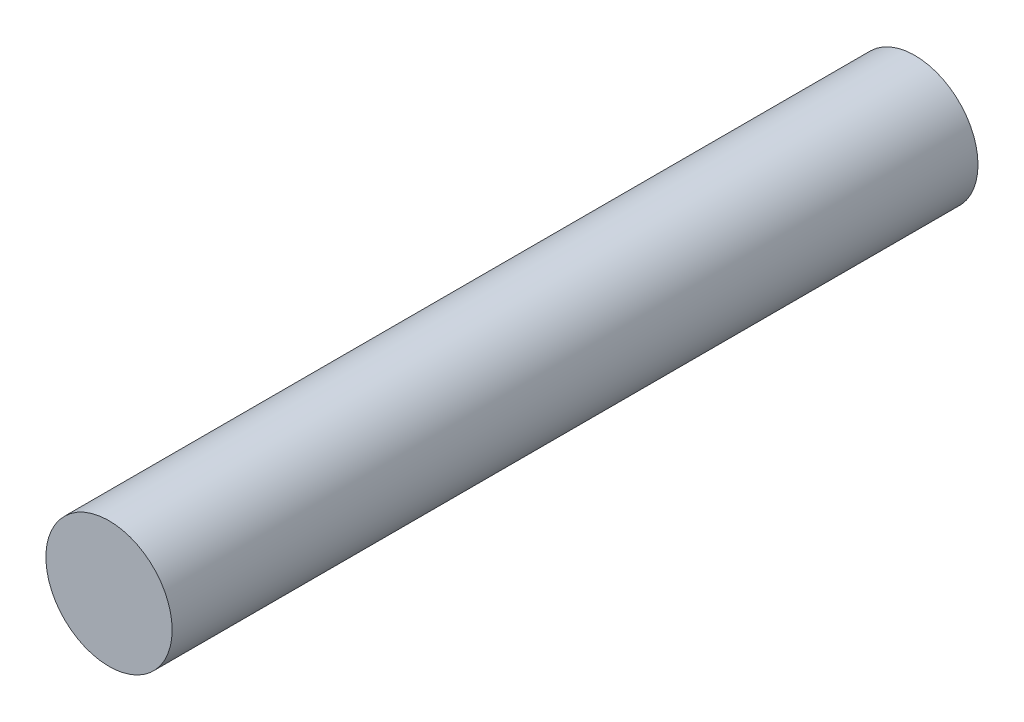
from build123d import *

# Parameters (mm, degrees)
ESQUISSE1_R      = 4.7
EXTRUSION1_DEPTH = 60


with BuildPart() as part:
    # Esquisse1 → Extrusion1 (new body)
    with BuildSketch(Plane.XY):
        Circle(ESQUISSE1_R)
    extrude(amount=EXTRUSION1_DEPTH)


solid = part.part
